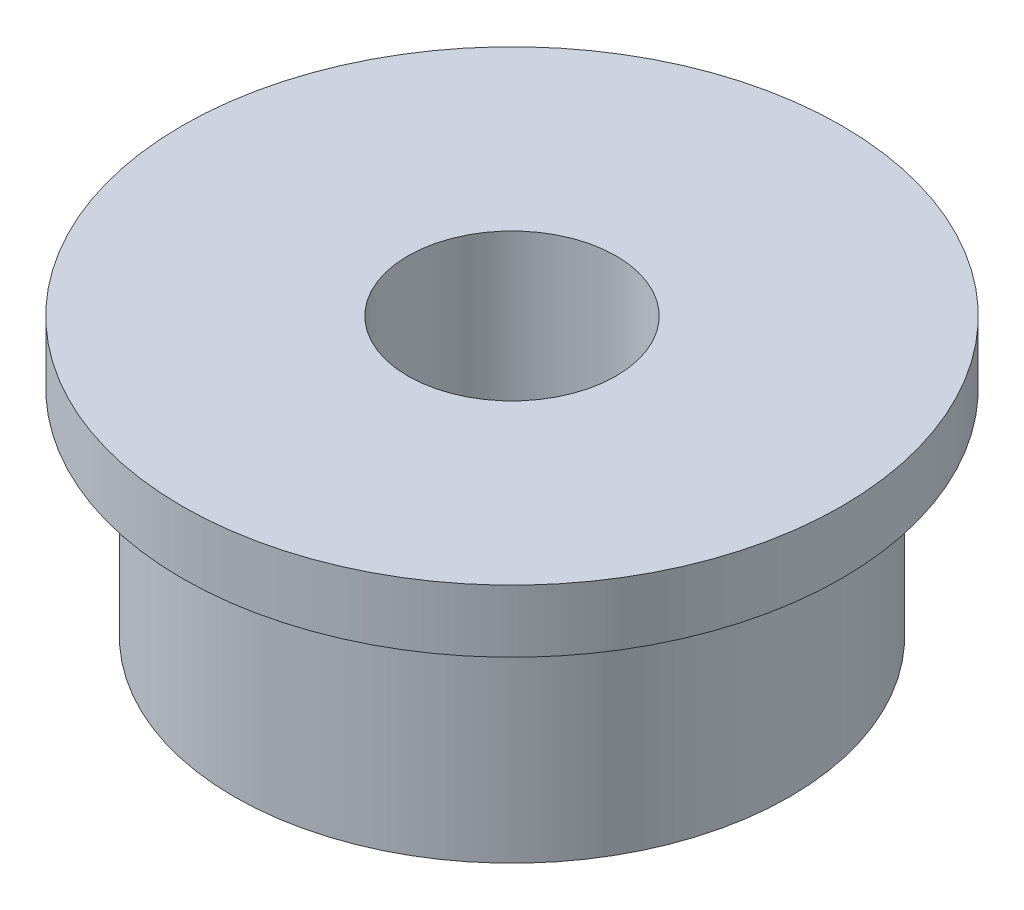
from build123d import *

# Parameters (mm, degrees)
SKETCH1_R           = 4
SKETCH1_R_2         = 1.5
BOSS_EXTRUDE1_DEPTH = 4
SKETCH2_R           = 4.75
SKETCH2_R_2         = 1.5
BOSS_EXTRUDE2_DEPTH = 0.9


with BuildPart() as part:
    # Sketch1 → Boss-Extrude1 (new body)
    with BuildSketch(Plane(origin=(0, 0, 0), x_dir=(1, 0, 0), z_dir=(0, 1, 0))):
        Circle(SKETCH1_R)
        Circle(SKETCH1_R_2, mode=Mode.SUBTRACT)
    extrude(amount=BOSS_EXTRUDE1_DEPTH)

    # Sketch2 → Boss-Extrude2 (add)
    with BuildSketch(Plane(origin=(0, 4, 0), x_dir=(1, 0, 0), z_dir=(0, 1, 0))):
        Circle(SKETCH2_R)
        Circle(SKETCH2_R_2, mode=Mode.SUBTRACT)
    extrude(amount=-BOSS_EXTRUDE2_DEPTH)


solid = part.part
